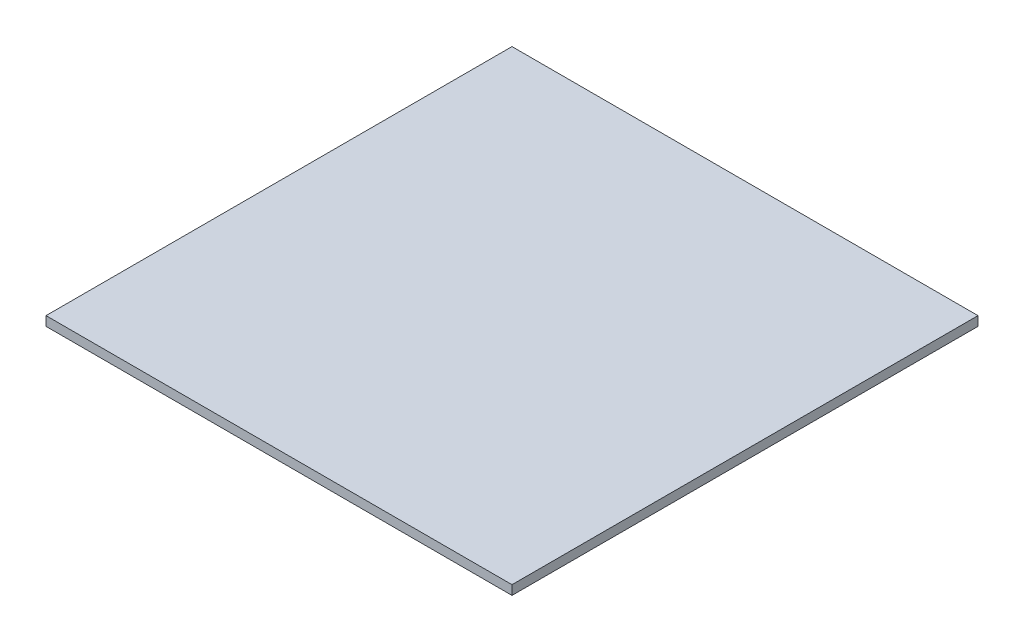
from build123d import *

# Parameters (mm, degrees)
ESQUISSE1_W      = 500
ESQUISSE1_H      = 500
EXTRUSION1_DEPTH = 10


with BuildPart() as part:
    # Esquisse1 → Extrusion1 (new body)
    with BuildSketch(Plane(origin=(0, 0, 0), x_dir=(1, 0, 0), z_dir=(0, 1, 0))):
        with Locations((250, 250)):
            Rectangle(ESQUISSE1_W, ESQUISSE1_H)
    extrude(amount=EXTRUSION1_DEPTH)


solid = part.part
